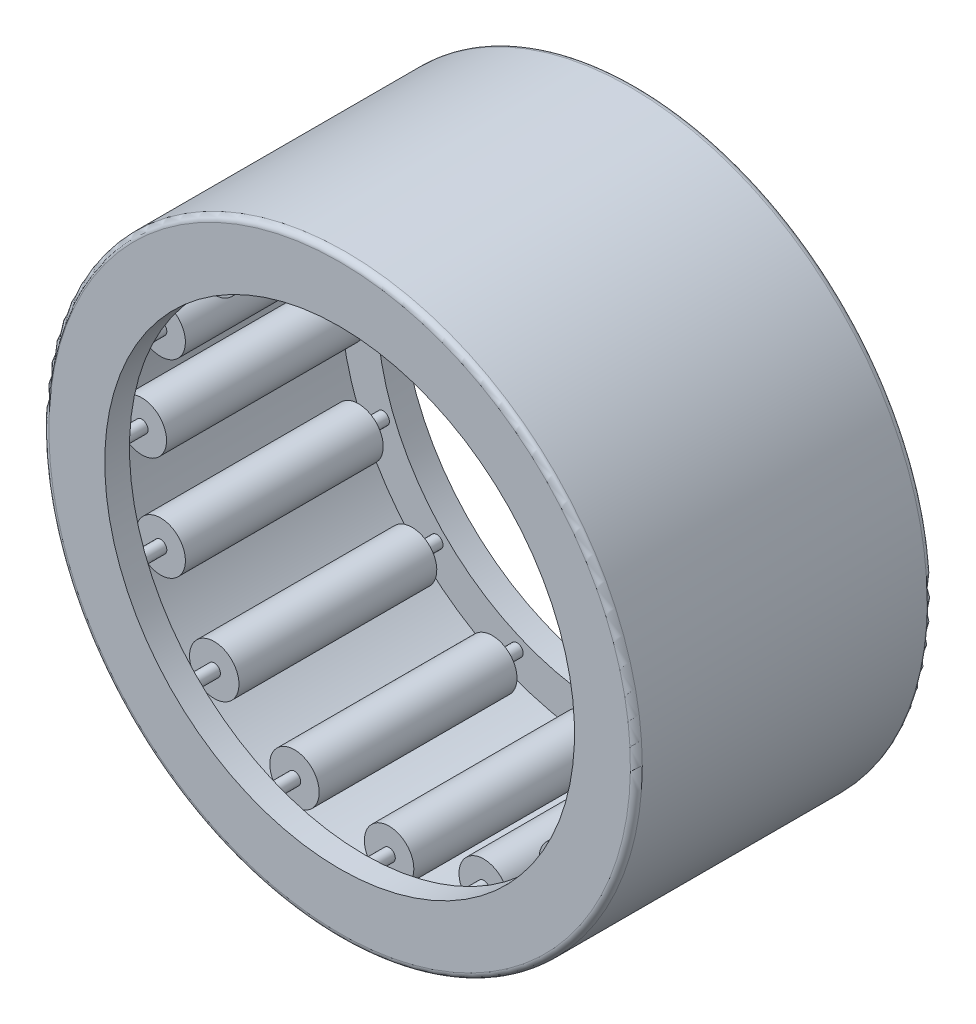
from build123d import *

# Parameters (mm, degrees)
SKETCH2_W         = 8.466666666
SKETCH2_H         = 0.79375
SKETCH3_W         = 10.583333334
SKETCH3_H         = 0.264583334
CIRPATTERN1_COUNT = 16
CIRPATTERN1_ANGLE = 337.5
FILLET1_R         = 0.254


with BuildPart() as part:
    # Sketch1 → Revolve1 (revolve)
    with BuildSketch(Plane(origin=(0, 0, 0), x_dir=(0, 0, -1), z_dir=(1, 0, 0))):
        Polygon((-6.35, 12.7), (6.35, 12.7), (6.35, 10.054166667), (5.291666667, 10.054166667), (5.291666667, 11.641666667), (-5.291666667, 11.641666667), (-5.291666667, 10.054166667), (-6.35, 10.054166667), align=None)
    revolve(axis=Axis((0, 0, 6.35), (0, 0, -1)))

    # Fillet1
    fillet1_edges = [part.edges().sort_by_distance(p)[0] for p in [
        (0, -12.7, 6.35),
        (0, -12.7, -6.35),
    ]]
    fillet(fillet1_edges, radius=FILLET1_R)


with BuildPart() as body_2:
    # Sketch2 → Revolve2 (revolve)
    with BuildSketch(Plane(origin=(0, 0, 0), x_dir=(0, 0, -1), z_dir=(1, 0, 0))):
        with Locations((0, 11.244791667)):
            Rectangle(SKETCH2_W, SKETCH2_H)
    revolve(axis=Axis((0, 10.583333333, 4.233333333), (0, 0, -1)))


with BuildPart() as body_3:
    # Sketch3 → Revolve3 (revolve)
    with BuildSketch(Plane(origin=(0, 0, 0), x_dir=(0, 0, -1), z_dir=(1, 0, 0))):
        with Locations((0, 10.715625)):
            Rectangle(SKETCH3_W, SKETCH3_H)
    revolve(axis=Axis((0, 10.583333333, 5.291666667), (0, 0, -1)))


with BuildPart() as cirpattern1_1:
    # CirPattern1: pattern copy
    add(body_2.part.rotate(Axis((0, 0, -6.35), (0, 0, 1)), 1 * CIRPATTERN1_ANGLE / (CIRPATTERN1_COUNT - 1)))


with BuildPart() as cirpattern1_2:
    # CirPattern1: pattern copy
    add(body_2.part.rotate(Axis((0, 0, -6.35), (0, 0, 1)), 2 * CIRPATTERN1_ANGLE / (CIRPATTERN1_COUNT - 1)))


with BuildPart() as cirpattern1_3:
    # CirPattern1: pattern copy
    add(body_2.part.rotate(Axis((0, 0, -6.35), (0, 0, 1)), 3 * CIRPATTERN1_ANGLE / (CIRPATTERN1_COUNT - 1)))


with BuildPart() as cirpattern1_4:
    # CirPattern1: pattern copy
    add(body_2.part.rotate(Axis((0, 0, -6.35), (0, 0, 1)), 4 * CIRPATTERN1_ANGLE / (CIRPATTERN1_COUNT - 1)))


with BuildPart() as cirpattern1_5:
    # CirPattern1: pattern copy
    add(body_2.part.rotate(Axis((0, 0, -6.35), (0, 0, 1)), 5 * CIRPATTERN1_ANGLE / (CIRPATTERN1_COUNT - 1)))


with BuildPart() as cirpattern1_6:
    # CirPattern1: pattern copy
    add(body_2.part.rotate(Axis((0, 0, -6.35), (0, 0, 1)), 6 * CIRPATTERN1_ANGLE / (CIRPATTERN1_COUNT - 1)))


with BuildPart() as cirpattern1_7:
    # CirPattern1: pattern copy
    add(body_2.part.rotate(Axis((0, 0, -6.35), (0, 0, 1)), 7 * CIRPATTERN1_ANGLE / (CIRPATTERN1_COUNT - 1)))


with BuildPart() as cirpattern1_8:
    # CirPattern1: pattern copy
    add(body_2.part.rotate(Axis((0, 0, -6.35), (0, 0, 1)), 8 * CIRPATTERN1_ANGLE / (CIRPATTERN1_COUNT - 1)))


with BuildPart() as cirpattern1_9:
    # CirPattern1: pattern copy
    add(body_2.part.rotate(Axis((0, 0, -6.35), (0, 0, 1)), 9 * CIRPATTERN1_ANGLE / (CIRPATTERN1_COUNT - 1)))


with BuildPart() as cirpattern1_10:
    # CirPattern1: pattern copy
    add(body_2.part.rotate(Axis((0, 0, -6.35), (0, 0, 1)), 10 * CIRPATTERN1_ANGLE / (CIRPATTERN1_COUNT - 1)))


with BuildPart() as cirpattern1_11:
    # CirPattern1: pattern copy
    add(body_2.part.rotate(Axis((0, 0, -6.35), (0, 0, 1)), 11 * CIRPATTERN1_ANGLE / (CIRPATTERN1_COUNT - 1)))


with BuildPart() as cirpattern1_12:
    # CirPattern1: pattern copy
    add(body_2.part.rotate(Axis((0, 0, -6.35), (0, 0, 1)), 12 * CIRPATTERN1_ANGLE / (CIRPATTERN1_COUNT - 1)))


with BuildPart() as cirpattern1_13:
    # CirPattern1: pattern copy
    add(body_2.part.rotate(Axis((0, 0, -6.35), (0, 0, 1)), 13 * CIRPATTERN1_ANGLE / (CIRPATTERN1_COUNT - 1)))


with BuildPart() as cirpattern1_14:
    # CirPattern1: pattern copy
    add(body_2.part.rotate(Axis((0, 0, -6.35), (0, 0, 1)), 14 * CIRPATTERN1_ANGLE / (CIRPATTERN1_COUNT - 1)))


with BuildPart() as cirpattern1_15:
    # CirPattern1: pattern copy
    add(body_2.part.rotate(Axis((0, 0, -6.35), (0, 0, 1)), 15 * CIRPATTERN1_ANGLE / (CIRPATTERN1_COUNT - 1)))


with BuildPart() as cirpattern1_16:
    # CirPattern1: pattern copy
    add(body_3.part.rotate(Axis((0, 0, -6.35), (0, 0, 1)), 1 * CIRPATTERN1_ANGLE / (CIRPATTERN1_COUNT - 1)))


with BuildPart() as cirpattern1_17:
    # CirPattern1: pattern copy
    add(body_3.part.rotate(Axis((0, 0, -6.35), (0, 0, 1)), 2 * CIRPATTERN1_ANGLE / (CIRPATTERN1_COUNT - 1)))


with BuildPart() as cirpattern1_18:
    # CirPattern1: pattern copy
    add(body_3.part.rotate(Axis((0, 0, -6.35), (0, 0, 1)), 3 * CIRPATTERN1_ANGLE / (CIRPATTERN1_COUNT - 1)))


with BuildPart() as cirpattern1_19:
    # CirPattern1: pattern copy
    add(body_3.part.rotate(Axis((0, 0, -6.35), (0, 0, 1)), 4 * CIRPATTERN1_ANGLE / (CIRPATTERN1_COUNT - 1)))


with BuildPart() as cirpattern1_20:
    # CirPattern1: pattern copy
    add(body_3.part.rotate(Axis((0, 0, -6.35), (0, 0, 1)), 5 * CIRPATTERN1_ANGLE / (CIRPATTERN1_COUNT - 1)))


with BuildPart() as cirpattern1_21:
    # CirPattern1: pattern copy
    add(body_3.part.rotate(Axis((0, 0, -6.35), (0, 0, 1)), 6 * CIRPATTERN1_ANGLE / (CIRPATTERN1_COUNT - 1)))


with BuildPart() as cirpattern1_22:
    # CirPattern1: pattern copy
    add(body_3.part.rotate(Axis((0, 0, -6.35), (0, 0, 1)), 7 * CIRPATTERN1_ANGLE / (CIRPATTERN1_COUNT - 1)))


with BuildPart() as cirpattern1_23:
    # CirPattern1: pattern copy
    add(body_3.part.rotate(Axis((0, 0, -6.35), (0, 0, 1)), 8 * CIRPATTERN1_ANGLE / (CIRPATTERN1_COUNT - 1)))


with BuildPart() as cirpattern1_24:
    # CirPattern1: pattern copy
    add(body_3.part.rotate(Axis((0, 0, -6.35), (0, 0, 1)), 9 * CIRPATTERN1_ANGLE / (CIRPATTERN1_COUNT - 1)))


with BuildPart() as cirpattern1_25:
    # CirPattern1: pattern copy
    add(body_3.part.rotate(Axis((0, 0, -6.35), (0, 0, 1)), 10 * CIRPATTERN1_ANGLE / (CIRPATTERN1_COUNT - 1)))


with BuildPart() as cirpattern1_26:
    # CirPattern1: pattern copy
    add(body_3.part.rotate(Axis((0, 0, -6.35), (0, 0, 1)), 11 * CIRPATTERN1_ANGLE / (CIRPATTERN1_COUNT - 1)))


with BuildPart() as cirpattern1_27:
    # CirPattern1: pattern copy
    add(body_3.part.rotate(Axis((0, 0, -6.35), (0, 0, 1)), 12 * CIRPATTERN1_ANGLE / (CIRPATTERN1_COUNT - 1)))


with BuildPart() as cirpattern1_28:
    # CirPattern1: pattern copy
    add(body_3.part.rotate(Axis((0, 0, -6.35), (0, 0, 1)), 13 * CIRPATTERN1_ANGLE / (CIRPATTERN1_COUNT - 1)))


with BuildPart() as cirpattern1_29:
    # CirPattern1: pattern copy
    add(body_3.part.rotate(Axis((0, 0, -6.35), (0, 0, 1)), 14 * CIRPATTERN1_ANGLE / (CIRPATTERN1_COUNT - 1)))


with BuildPart() as cirpattern1_30:
    # CirPattern1: pattern copy
    add(body_3.part.rotate(Axis((0, 0, -6.35), (0, 0, 1)), 15 * CIRPATTERN1_ANGLE / (CIRPATTERN1_COUNT - 1)))


solid = Compound([part.part, body_2.part, body_3.part, cirpattern1_1.part, cirpattern1_2.part, cirpattern1_3.part, cirpattern1_4.part, cirpattern1_5.part, cirpattern1_6.part, cirpattern1_7.part, cirpattern1_8.part, cirpattern1_9.part, cirpattern1_10.part, cirpattern1_11.part, cirpattern1_12.part, cirpattern1_13.part, cirpattern1_14.part, cirpattern1_15.part, cirpattern1_16.part, cirpattern1_17.part, cirpattern1_18.part, cirpattern1_19.part, cirpattern1_20.part, cirpattern1_21.part, cirpattern1_22.part, cirpattern1_23.part, cirpattern1_24.part, cirpattern1_25.part, cirpattern1_26.part, cirpattern1_27.part, cirpattern1_28.part, cirpattern1_29.part, cirpattern1_30.part])
